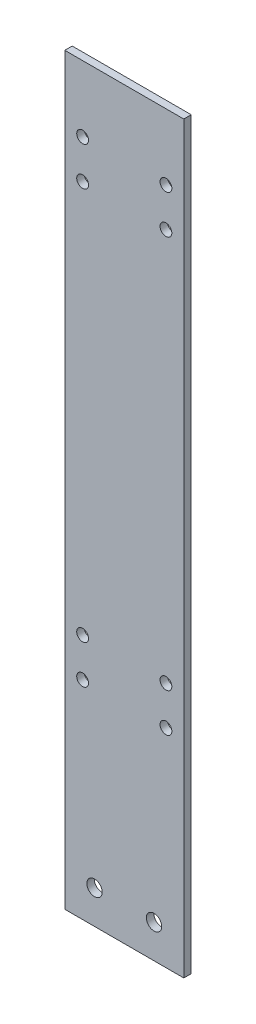
from build123d import *

# Parameters (mm, degrees)
SKETCH1_W           = 101.6
SKETCH1_H           = 6.35
BOSS_EXTRUDE1_DEPTH = 635
SKETCH2_R           = 6.54812
SKETCH2_R_2         = 5.0419
CUT_EXTRUDE1_DEPTH  = 6.35


with BuildPart() as part:
    # Sketch1 → Boss-Extrude1 (new body)
    with BuildSketch(Plane(origin=(0, 0, 0), x_dir=(1, 0, 0), z_dir=(0, 1, 0))):
        with Locations((50.8, 3.175)):
            Rectangle(SKETCH1_W, SKETCH1_H)
    extrude(amount=BOSS_EXTRUDE1_DEPTH)

    # Sketch2 → Cut-Extrude1 (cut)
    with BuildSketch(Plane.XY):
        with Locations((25.4, 28.575)):
            Circle(SKETCH2_R)
        with Locations((76.2, 28.575)):
            Circle(SKETCH2_R)
        with Locations((15.24, 210.312)):
            Circle(SKETCH2_R_2)
        with Locations((86.36, 210.312)):
            Circle(SKETCH2_R_2)
        with Locations((15.24, 177.292)):
            Circle(SKETCH2_R_2)
        with Locations((86.36, 177.292)):
            Circle(SKETCH2_R_2)
        with Locations((15.24, 578.612)):
            Circle(SKETCH2_R_2)
        with Locations((15.24, 545.592)):
            Circle(SKETCH2_R_2)
        with Locations((86.36, 578.612)):
            Circle(SKETCH2_R_2)
        with Locations((86.36, 545.592)):
            Circle(SKETCH2_R_2)
    extrude(amount=-CUT_EXTRUDE1_DEPTH, mode=Mode.SUBTRACT)


solid = part.part
